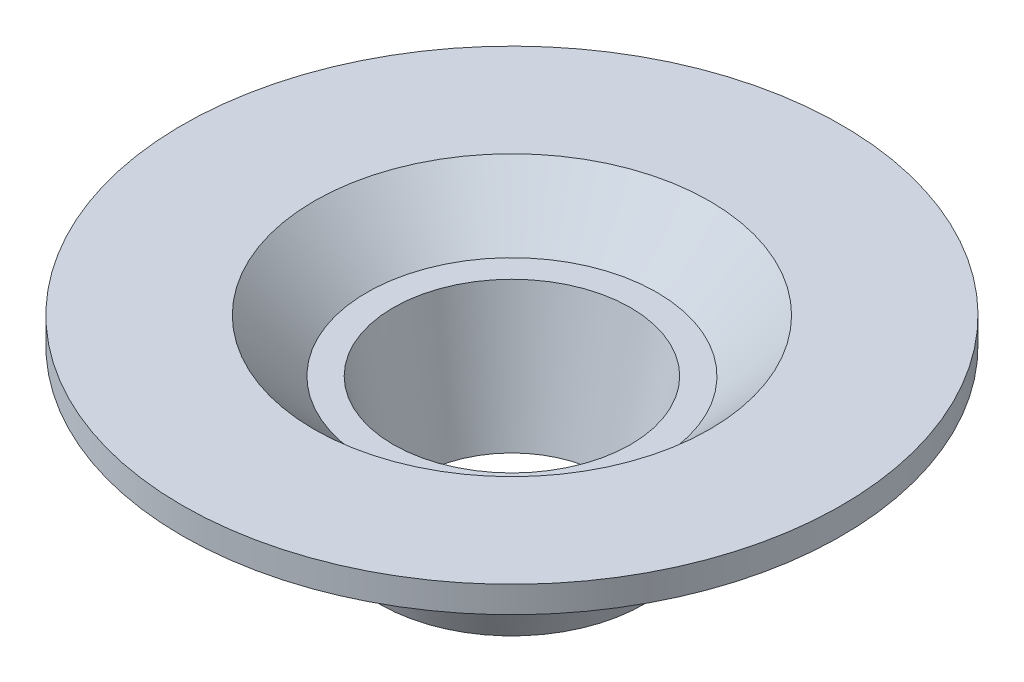
from build123d import *


with BuildPart() as part:
    # Sketch1 → Revolve1 (revolve)
    with BuildSketch(Plane(origin=(0, 0, 0), x_dir=(0, 0, -1), z_dir=(1, 0, 0))):
        Polygon((4.5, 0), (3.5, -5), (5, -5), (6.5, -1), (8.5, -1), (10.5, 1), (12.5, 1), (12.5, 2), (7.5, 2), (5.5, 0), align=None)
    revolve(axis=Axis((0, 0, 0), (0, -1, 0)))


solid = part.part
